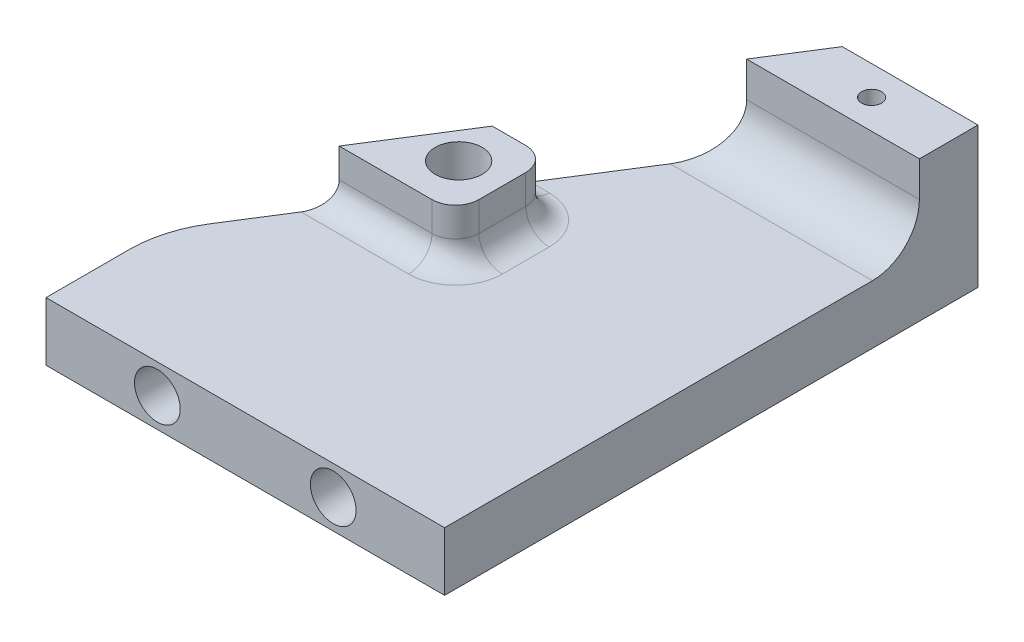
from build123d import *

# Parameters (mm, degrees)
SKETCH1_W           = 34
SKETCH1_H           = 29
SKETCH1_R           = 1.4
SKETCH1_R_2         = 1.5
BOSS_EXTRUDE1_DEPTH = 5
BOSS_EXTRUDE2_DEPTH = 5
SKETCH3_R           = 0.85
BOSS_EXTRUDE3_DEPTH = 7
CUT_EXTRUDE2_DEPTH  = 5
FILLET1_R           = 4
SKETCH7_W           = 5
SKETCH7_H           = 34
CUT_EXTRUDE3_DEPTH  = 44
SKETCH8_R           = 1.95
CUT_EXTRUDE4_DEPTH  = 6
FILLET2_R           = 10
BOSS_EXTRUDE4_DEPTH = 4.5
CUT_EXTRUDE5_START  = 4.5
SKETCH9_R           = 2
CUT_EXTRUDE5_DEPTH  = 5
FILLET3_R           = 2


with BuildPart() as part:
    # Sketch1 → Boss-Extrude1 (new body)
    with BuildSketch(Plane.XY):
        with Locations((7.610207842, -10)):
            Rectangle(SKETCH1_W, SKETCH1_H)
        with Locations((15.010207842, 0)):
            Circle(SKETCH1_R, mode=Mode.SUBTRACT)
        with Locations((15.010207842, -20)):
            Circle(SKETCH1_R, mode=Mode.SUBTRACT)
        with Locations((0.010207842, 0)):
            Circle(SKETCH1_R_2, mode=Mode.SUBTRACT)
        with Locations((0.010207842, -20)):
            Circle(SKETCH1_R_2, mode=Mode.SUBTRACT)
    extrude(amount=BOSS_EXTRUDE1_DEPTH)

    # Sketch2 → Boss-Extrude2 (add)
    with BuildSketch(Plane.XZ.offset(24.5)):
        Polygon((-9.389792158, -10), (-9.389792158, 5), (24.610207842, 5), (24.610207842, -48), (14.610207842, -48), align=None)
    extrude(amount=BOSS_EXTRUDE2_DEPTH)

    # Sketch3 → Boss-Extrude3 (add)
    with BuildSketch(Plane(origin=(0, -24.5, 0), x_dir=(1, 0, 0), z_dir=(0, 1, 0))):
        Polygon((24.610207842, 40.5), (9.873365737, 40.5), (13.031260474, 45.5), (24.610207842, 45.5), align=None)
        with Locations(Location((18.031260474, 43, 0), (0, 0, 270))):  # turned: the seam where the file's is
            Circle(SKETCH3_R, mode=Mode.SUBTRACT)
    extrude(amount=BOSS_EXTRUDE3_DEPTH)

    # Sketch6 → Cut-Extrude2 (cut)
    with BuildSketch(Plane(origin=(0, -24.5, 0), x_dir=(1, 0, 0), z_dir=(0, 1, 0))):
        Polygon((13.031260474, 45.5), (24.610207842, 45.5), (24.610207842, 48), (14.610207842, 48), align=None)
    extrude(amount=-CUT_EXTRUDE2_DEPTH, mode=Mode.SUBTRACT)

    # Fillet1
    fillet1_edges = [part.edges().sort_by_distance(p)[0] for p in [
        (17.24178679, -24.5, -40.5),
    ]]
    fillet(fillet1_edges, radius=FILLET1_R)

    # Sketch7 → Cut-Extrude3 (cut)
    with BuildSketch(Plane.ZY.offset(9.389792158)):
        with Locations((2.5, -12.5)):
            Rectangle(SKETCH7_W, SKETCH7_H)
    extrude(amount=-CUT_EXTRUDE3_DEPTH, mode=Mode.SUBTRACT)

    # Sketch8 → Cut-Extrude4 (cut)
    with BuildSketch(Plane.XY):
        with Locations((15.110207842, -27)):
            Circle(SKETCH8_R)
        with Locations(Location((0.110207842, -27, 0), (0, 0, 180))):  # turned: the seam where the file's is
            Circle(SKETCH8_R)
    extrude(amount=-CUT_EXTRUDE4_DEPTH, mode=Mode.SUBTRACT)

    # Fillet2
    fillet2_edges = [part.edges().sort_by_distance(p)[0] for p in [
        (-9.389792158, -27, -10),
    ]]
    fillet(fillet2_edges, radius=FILLET2_R)

    # Sketch11 → Boss-Extrude4 (add)
    with BuildSketch(Plane(origin=(0, -24.5, 0), x_dir=(1, 0, 0), z_dir=(0, 1, 0))):
        with BuildLine():
            Line((1.473365737, 27.2), (4.332633033, 27.2))
            ThreePointArc((4.332633033, 27.2), (5.746846596, 26.614213562), (6.332633033, 25.2))
            Line((6.332633033, 25.2), (6.332633033, 21.2))
            ThreePointArc((6.332633033, 21.2), (5.746846596, 19.785786438), (4.332633033, 19.2))
            Line((4.332633033, 19.2), (-3.579265842, 19.2))
            Line((-3.579265842, 19.2), (1.473365737, 27.2))
        make_face()
    extrude(amount=BOSS_EXTRUDE4_DEPTH)

    # Sketch9 → Cut-Extrude5 (cut)
    with BuildSketch(Plane(origin=(0, -24.5, 0), x_dir=(1, 0, 0), z_dir=(0, 1, 0)).offset(CUT_EXTRUDE5_START)):
        with Locations(Location((2.610207842, 23.2, 0), (0, 0, 90))):  # turned: the seam where the file's is
            Circle(SKETCH9_R)
    extrude(amount=-CUT_EXTRUDE5_DEPTH, mode=Mode.SUBTRACT)

    # Fillet3
    fillet3_edges = [part.edges().sort_by_distance(p)[0] for p in [
        (0.376683596, -24.5, -19.2),
        (5.746846596, -24.5, -19.785786438),
        (6.332633033, -24.5, -23.2),
        (5.746846596, -24.5, -26.614213562),
        (2.902999385, -24.5, -27.2),
    ]]
    fillet(fillet3_edges, radius=FILLET3_R)


solid = part.part
